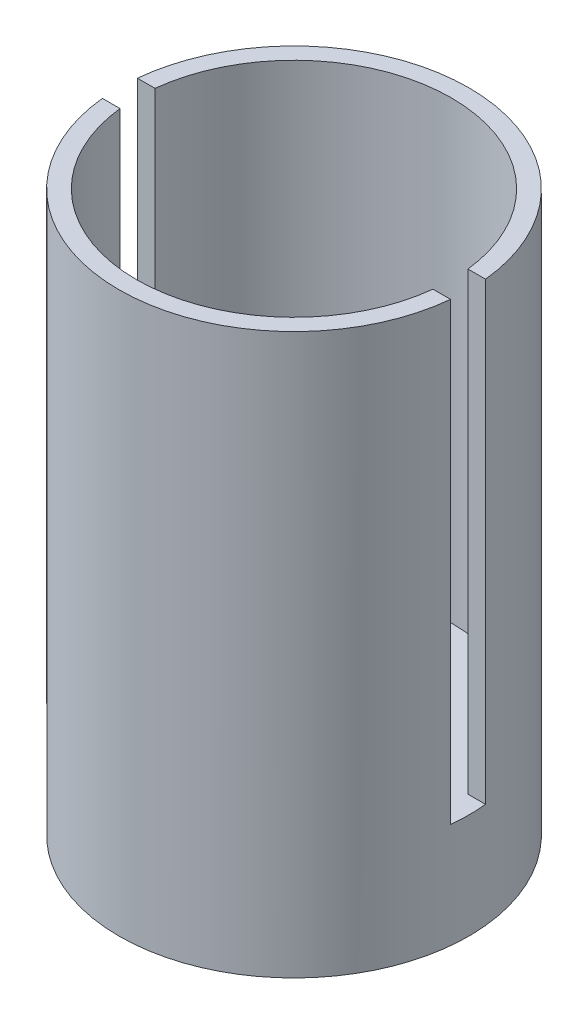
from build123d import *

# Parameters (mm, degrees)
SKETCH1_R           = 25
SKETCH1_R_2         = 22.5
BOSS_EXTRUDE1_DEPTH = 80
SKETCH2_R           = 25
BOSS_EXTRUDE2_DEPTH = 15
SKETCH3_W           = 50
SKETCH3_H           = 5
CUT_EXTRUDE1_DEPTH  = 65
SKETCH4_R           = 5
CUT_EXTRUDE2_DEPTH  = 10


with BuildPart() as part:
    # Sketch1 → Boss-Extrude1 (new body)
    with BuildSketch(Plane(origin=(0, 0, 0), x_dir=(1, 0, 0), z_dir=(0, 1, 0))):
        Circle(SKETCH1_R)
        Circle(SKETCH1_R_2, mode=Mode.SUBTRACT)
    extrude(amount=BOSS_EXTRUDE1_DEPTH)

    # Sketch2 → Boss-Extrude2 (add)
    with BuildSketch(Plane.XZ):
        Circle(SKETCH2_R)
    extrude(amount=-BOSS_EXTRUDE2_DEPTH)

    # Sketch3 → Cut-Extrude1 (cut)
    with BuildSketch(Plane(origin=(0, 80, 0), x_dir=(1, 0, 0), z_dir=(0, 1, 0))):
        Rectangle(SKETCH3_W, SKETCH3_H)
    extrude(amount=-CUT_EXTRUDE1_DEPTH, mode=Mode.SUBTRACT)

    # Sketch4 → Cut-Extrude2 (cut)
    with BuildSketch(Plane(origin=(0, 15, 0), x_dir=(1, 0, 0), z_dir=(0, 1, 0))):
        Circle(SKETCH4_R)
    extrude(amount=-CUT_EXTRUDE2_DEPTH, mode=Mode.SUBTRACT)


solid = part.part
